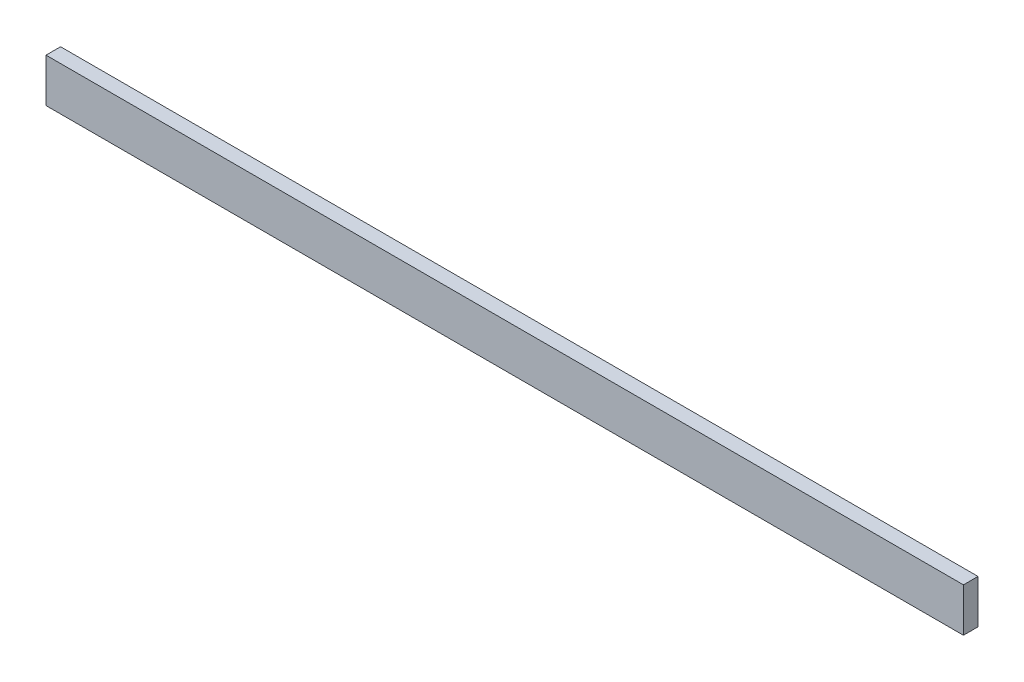
from build123d import *

# Parameters (mm, degrees)
SKETCH1_W           = 400.05
SKETCH1_H           = 19.05
BOSS_EXTRUDE1_DEPTH = 6.35


with BuildPart() as part:
    # Sketch1 → Boss-Extrude1 (new body)
    with BuildSketch(Plane.XY):
        with Locations((200.025, 9.525)):
            Rectangle(SKETCH1_W, SKETCH1_H)
    extrude(amount=BOSS_EXTRUDE1_DEPTH)


solid = part.part
